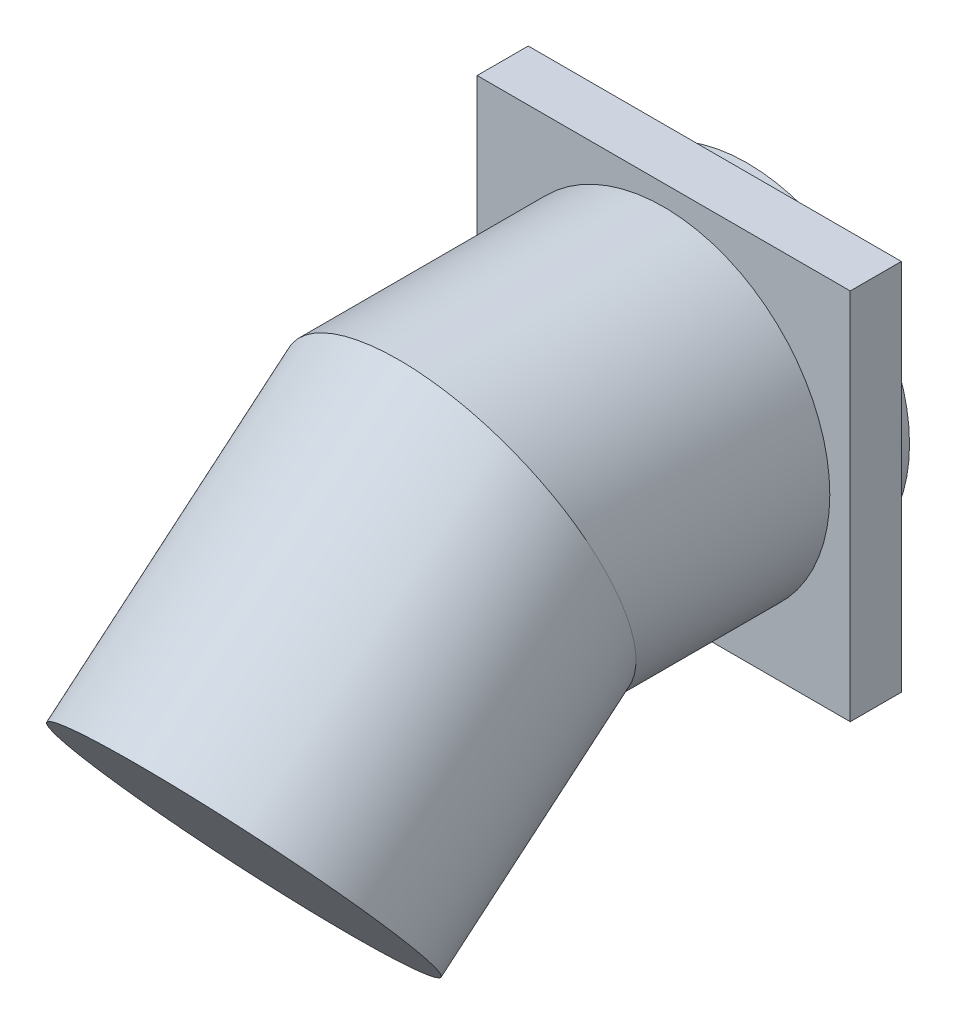
from build123d import *

# Parameters (mm, degrees)
SKETCH1_W           = 146
SKETCH1_H           = 146
BOSS_EXTRUDE1_DEPTH = 20
SKETCH2_R           = 63.5
BOSS_EXTRUDE2_DEPTH = 12.7
SKETCH3_R           = 65


with BuildPart() as part:
    # Sketch1 → Boss-Extrude1 (new body)
    with BuildSketch(Plane.XY):
        Rectangle(SKETCH1_W, SKETCH1_H)
    extrude(amount=BOSS_EXTRUDE1_DEPTH)

    # Sketch2 → Boss-Extrude2 (add)
    with BuildSketch(Plane(origin=(0, 0, 0), x_dir=(-1, 0, 0), z_dir=(0, 0, -1))):
        Circle(SKETCH2_R)
    extrude(amount=BOSS_EXTRUDE2_DEPTH)

    # Sweep1: sweep along a path in Sketch4
    with BuildLine(Plane(origin=(0, 0, 0), x_dir=(0, 0, -1), z_dir=(1, 0, 0))) as sweep1_path:
        Line((-20, 0), (-100, 0))
        Line((-100, 0), (-184.264888743, -70.706637066))
    # Sketch3 → Sweep1 (sweep)
    with BuildSketch(Plane.XY.offset(20)):
        Circle(SKETCH3_R)
    sweep(path=sweep1_path.line, transition=Transition.RIGHT)


solid = part.part
